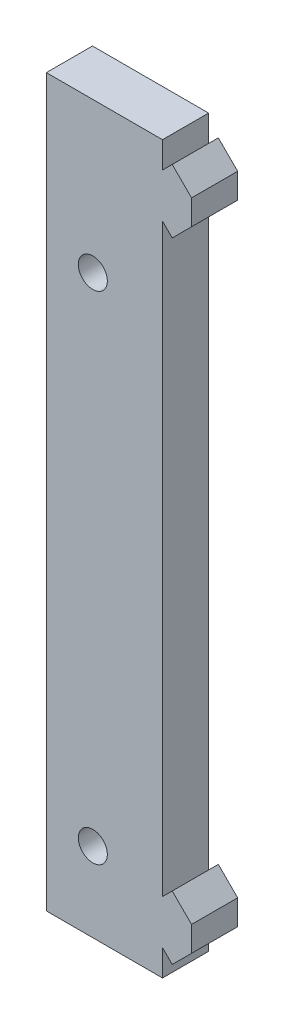
from build123d import *

# Parameters (mm, degrees)
SKETCH1_R           = 1.5
BOSS_EXTRUDE1_DEPTH = 4.7625


with BuildPart() as part:
    # Sketch1 → Boss-Extrude1 (new body)
    with BuildSketch(Plane.XY):
        Polygon((0, -2.716800154), (1.004846686, -1.711953467), (3, -3.707106781), (3, -6.292893219), (1.004846686, -8.288046533), (0, -7.283199846), (0, -67.716800154), (1.004846686, -66.711953467), (3, -68.707106781), (3, -71.292893219), (1.004846686, -73.288046533), (0, -72.283199846), (0, -75), (-12, -75), (-12, 0), (0, 0), align=None)
        with Locations((-7.2, -15.5)):
            Circle(SKETCH1_R, mode=Mode.SUBTRACT)
        with Locations((-7.2, -66.8)):
            Circle(SKETCH1_R, mode=Mode.SUBTRACT)
    extrude(amount=BOSS_EXTRUDE1_DEPTH)


solid = part.part
